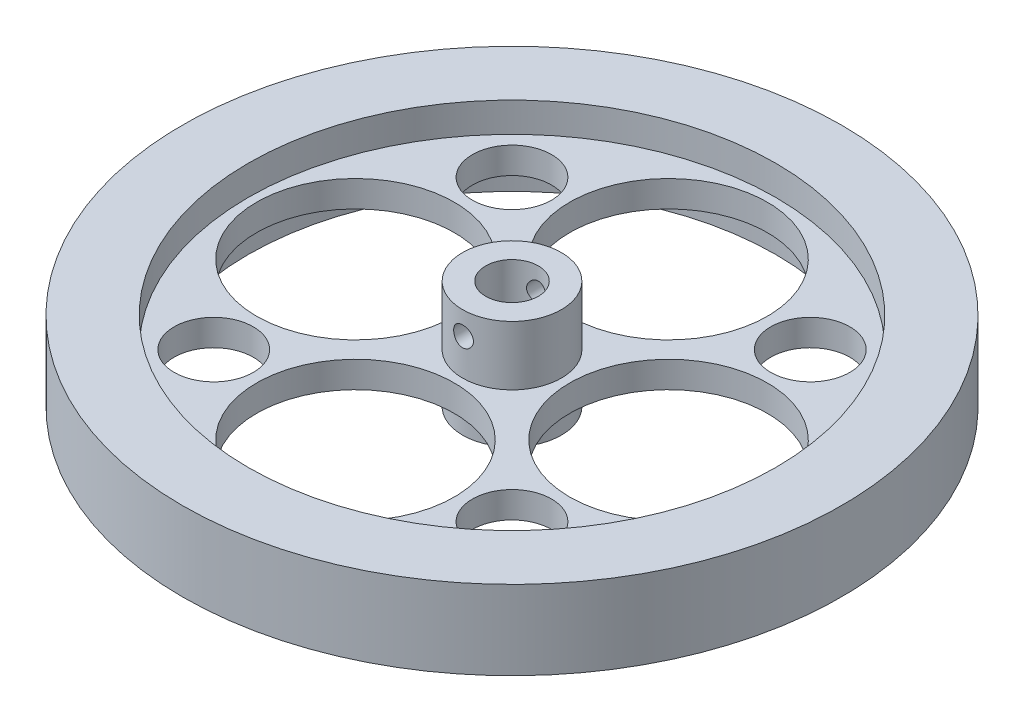
from build123d import *

# Parameters (mm, degrees)
SKETCH1_R               = 50
SKETCH1_R_2             = 40
BOSS_EXTRUDE1_DEPTH     = 12
SKETCH1_4_R             = 7.5
SKETCH1_4_R_2           = 4
BOSS_EXTRUDE2_DEPTH     = 16.5
BOSS_EXTRUDE3_START     = 3.5
SKETCH1_5_R             = 40
SKETCH1_5_R_2           = 7.5
BOSS_EXTRUDE3_DEPTH     = 4
CUT_EXTRUDE3_DEPTH      = 73.610260983
CUT_EXTRUDE3_DEPTH_BACK = 73.610260983
SKETCH2_R               = 15
SKETCH2_R_2             = 6
CUT_EXTRUDE4_DEPTH      = 10
CUT_EXTRUDE4_DEPTH_BACK = 10


with BuildPart() as part:
    # Sketch1 → Boss-Extrude1 (new body)
    with BuildSketch(Plane(origin=(0, 0, 0), x_dir=(1, 0, 0), z_dir=(0, 1, 0))):
        Circle(SKETCH1_R)
        Circle(SKETCH1_R_2, mode=Mode.SUBTRACT)
    extrude(amount=BOSS_EXTRUDE1_DEPTH)



with BuildPart() as body_2:
    # Sketch1_4 → Boss-Extrude2 (new body)
    with BuildSketch(Plane(origin=(0, 0, 0), x_dir=(1, 0, 0), z_dir=(0, 1, 0))):
        Circle(SKETCH1_4_R)
        Circle(SKETCH1_4_R_2, mode=Mode.SUBTRACT)
    extrude(amount=BOSS_EXTRUDE2_DEPTH)


with BuildPart() as part_1:
    add(part.part)

    add(body_2.part)  # Boss-Extrude3 merges body 2
    # Sketch1_5 → Boss-Extrude3 (add)
    with BuildSketch(Plane(origin=(0, 0, 0), x_dir=(1, 0, 0), z_dir=(0, 1, 0)).offset(BOSS_EXTRUDE3_START)):
        Circle(SKETCH1_5_R)
        Circle(SKETCH1_5_R_2, mode=Mode.SUBTRACT)
    extrude(amount=BOSS_EXTRUDE3_DEPTH)

    # Sketch2 → Cut-Extrude3 (cut, two sides: drawn at the far end of the back side and taken through both)
    with BuildSketch(Plane(origin=(0, 0, 0), x_dir=(1, 0, 0), z_dir=(0, 1, 0)).offset(-CUT_EXTRUDE3_DEPTH_BACK)):
        with Locations((0, 23.75)):
            Circle(SKETCH2_R)
        with Locations((23.75, 0)):
            Circle(SKETCH2_R)
        with Locations((0, -23.75)):
            Circle(SKETCH2_R)
        with Locations((-23.75, 0)):
            Circle(SKETCH2_R)
        with Locations((-22.627416998, 22.627416998)):
            Circle(SKETCH2_R_2)
        with Locations((22.627416998, 22.627416998)):
            Circle(SKETCH2_R_2)
        with Locations((22.627416998, -22.627416998)):
            Circle(SKETCH2_R_2)
        with Locations((-22.627416998, -22.627416998)):
            Circle(SKETCH2_R_2)
    extrude(amount=CUT_EXTRUDE3_DEPTH + CUT_EXTRUDE3_DEPTH_BACK, mode=Mode.SUBTRACT)

    # Sketch3 → Cut-Extrude4 (cut, two sides: drawn at the far end of the back side and taken through both)
    with BuildSketch(Plane.XY.offset(-CUT_EXTRUDE4_DEPTH_BACK)):
        with BuildLine():
            ThreePointArc((0, 14.5), (-1.060660172, 11.939339828), (1.5, 13))
            ThreePointArc((1.5, 13), (1.060660172, 14.060660172), (0, 14.5))
        make_face()
    extrude(amount=CUT_EXTRUDE4_DEPTH + CUT_EXTRUDE4_DEPTH_BACK, mode=Mode.SUBTRACT)


solid = part_1.part
